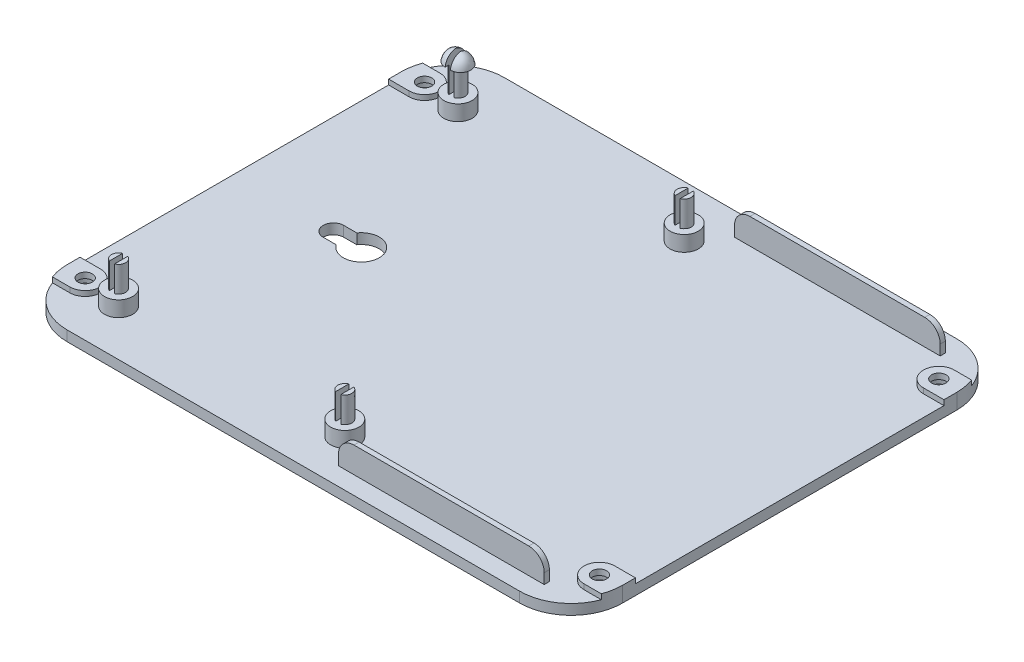
from build123d import *

# Parameters (mm, degrees)
BOSS_EXTRUDE2_DEPTH = 2
CUT_EXTRUDE2_DEPTH  = 7
SKETCH10_W          = 40
SKETCH10_H          = 1
BOSS_EXTRUDE3_DEPTH = 7
CUT_EXTRUDE4_DEPTH  = 1
CUT_EXTRUDE5_DEPTH  = 1
SKETCH14_R          = 1.375
BOSS_EXTRUDE4_DEPTH = 10
SKETCH15_R          = 2.75
BOSS_EXTRUDE5_DEPTH = 5
BOSS_EXTRUDE8_DEPTH = 3
SKETCH21_R          = 3
CUT_EXTRUDE7_DEPTH  = 1.9
SKETCH22_R          = 1.4
CUT_EXTRUDE8_DEPTH  = 15
SKETCH24_W          = 1
SKETCH24_H          = 3.418232964
SKETCH24_H_2        = 3.173713674
SKETCH24_H_3        = 3.19842194
CUT_EXTRUDE10_DEPTH = 5
REVOLVE1_ANGLE      = 180
REVOLVE2_ANGLE      = 180


with BuildPart() as part:
    # Sketch3 → Boss-Extrude2 (new body)
    with BuildSketch(Plane(origin=(0, 0, 0), x_dir=(1, 0, 0), z_dir=(0, 1, 0))):
        with BuildLine():
            Line((-30.001043465, -34.015189653), (57.998956535, -34.015189653))
            ThreePointArc((57.998956535, -34.015189653), (65.070024347, -31.086257464), (67.998956535, -24.015189653))
            Line((67.998956535, -24.015189653), (67.998956535, 40.984810347))
            ThreePointArc((67.998956535, 40.984810347), (65.070024347, 48.055878159), (57.998956535, 50.984810347))
            Line((57.998956535, 50.984810347), (-30.001043465, 50.984810347))
            ThreePointArc((-30.001043465, 50.984810347), (-37.072111277, 48.055878159), (-40.001043465, 40.984810347))
            Line((-40.001043465, 40.984810347), (-40.001043465, -24.015189653))
            ThreePointArc((-40.001043465, -24.015189653), (-37.072111277, -31.086257464), (-30.001043465, -34.015189653))
        make_face()
    extrude(amount=BOSS_EXTRUDE2_DEPTH)

    # Sketch6 → Cut-Extrude2 (cut)
    with BuildSketch(Plane(origin=(0, 2, 0), x_dir=(1, 0, 0), z_dir=(0, 1, 0))):
        with BuildLine():
            Line((-18.182060551, 10.483778137), (-20.721753803, 10.483778137))
            ThreePointArc((-20.721753803, 10.483778137), (-22.720721593, 8.484810347), (-20.721753803, 6.485842558))
            Line((-20.721753803, 6.485842558), (-18.182060551, 6.485842558))
            ThreePointArc((-18.182060551, 6.485842558), (-11.809060764, 8.484810347), (-18.182060551, 10.483778137))
        make_face()
    extrude(amount=-CUT_EXTRUDE2_DEPTH, mode=Mode.SUBTRACT)

    # Sketch10 → Boss-Extrude3 (add)
    with BuildSketch(Plane(origin=(0, 0, 0), x_dir=(1, 0, 0), z_dir=(0, 1, 0))):
        with Locations((39.263184903, 46.984810347)):
            Rectangle(SKETCH10_W, SKETCH10_H)
        with Locations((39.263184903, -30.015189653)):
            Rectangle(SKETCH10_W, SKETCH10_H)
    extrude(amount=BOSS_EXTRUDE3_DEPTH)

    # Sketch12 → Cut-Extrude4 (cut)
    with BuildSketch(Plane.XY.offset(30.515189653)):
        with BuildLine():
            Line((56.263184903, 7), (59.263184903, 7))
            Line((59.263184903, 7), (59.263184903, 4))
            ThreePointArc((59.263184903, 4), (58.384505246, 6.121320344), (56.263184903, 7))
        make_face()
        with BuildLine():
            Line((19.263184903, 4), (19.263184903, 7))
            Line((19.263184903, 7), (22.263184903, 7))
            ThreePointArc((22.263184903, 7), (20.141864559, 6.121320344), (19.263184903, 4))
        make_face()
    extrude(amount=-CUT_EXTRUDE4_DEPTH, mode=Mode.SUBTRACT)

    # Sketch13 → Cut-Extrude5 (cut)
    with BuildSketch(Plane(origin=(0, 0, -47.484810347), x_dir=(-1, 0, 0), z_dir=(0, 0, -1))):
        with BuildLine():
            Line((-56.263184903, 7), (-59.263184903, 7))
            Line((-59.263184903, 7), (-59.263184903, 4))
            ThreePointArc((-59.263184903, 4), (-58.384505246, 6.121320344), (-56.263184903, 7))
        make_face()
        with BuildLine():
            Line((-19.263184903, 4), (-19.263184903, 7))
            Line((-19.263184903, 7), (-22.263184903, 7))
            ThreePointArc((-22.263184903, 7), (-20.141864559, 6.121320344), (-19.263184903, 4))
        make_face()
    extrude(amount=-CUT_EXTRUDE5_DEPTH, mode=Mode.SUBTRACT)

    # Sketch14 → Boss-Extrude4 (add)
    with BuildSketch(Plane.XZ):
        with Locations(Location((-29.011006112, 25.011760646, 0), (0, 0, 270))):
            Circle(SKETCH14_R)
        with Locations(Location((14.981881874, 25.011760646, 0), (0, 0, 270))):
            Circle(SKETCH14_R)
        with Locations(Location((14.981881874, -40.988239354, 0), (0, 0, 270))):
            Circle(SKETCH14_R)
        with Locations(Location((-29.011006112, -40.988239354, 0), (0, 0, 270))):
            Circle(SKETCH14_R)
    extrude(amount=-BOSS_EXTRUDE4_DEPTH)

    # Sketch15 → Boss-Extrude5 (add)
    with BuildSketch(Plane.XZ):
        with Locations(Location((-29.011006112, 25.011760646, 0), (0, 0, 270))):
            Circle(SKETCH15_R)
        with Locations(Location((14.981881874, 25.011760646, 0), (0, 0, 270))):
            Circle(SKETCH15_R)
        with Locations(Location((14.981881874, -40.988239354, 0), (0, 0, 270))):
            Circle(SKETCH15_R)
        with Locations(Location((-29.011006112, -40.988239354, 0), (0, 0, 270))):
            Circle(SKETCH15_R)
    extrude(amount=-BOSS_EXTRUDE5_DEPTH)

    # Sketch5 → Boss-Extrude8 (add)
    with BuildSketch(Plane(origin=(0, 0, 34.015189653), x_dir=(1, 0, 0), z_dir=(0, 1, 0))):
        with BuildLine():
            Line((-36.001043465, 78.5), (-39.368540462, 78.5))
            ThreePointArc((-39.368540462, 78.5), (-39.841647358, 76.778346145), (-40.001043465, 75))
            Line((-40.001043465, 75), (-40.001043465, 72.5))
            Line((-40.001043465, 72.5), (-36.001043465, 72.5))
            ThreePointArc((-36.001043465, 72.5), (-33.001043465, 75.5), (-36.001043465, 78.5))
        make_face()
        with BuildLine():
            Line((63.998956535, 78.5), (67.366453533, 78.5))
            ThreePointArc((67.366453533, 78.5), (67.839560429, 76.778346145), (67.998956535, 75))
            Line((67.998956535, 75), (67.998956535, 72.5))
            Line((67.998956535, 72.5), (63.998956535, 72.5))
            ThreePointArc((63.998956535, 72.5), (60.998956535, 75.5), (63.998956535, 78.5))
        make_face()
        with BuildLine():
            Line((63.998956535, 12.5), (67.998956535, 12.5))
            Line((67.998956535, 12.5), (67.998956535, 10))
            ThreePointArc((67.998956535, 10), (67.839560429, 8.221653855), (67.366453533, 6.5))
            Line((67.366453533, 6.5), (63.998956535, 6.5))
            ThreePointArc((63.998956535, 6.5), (60.998956535, 9.5), (63.998956535, 12.5))
        make_face()
        with BuildLine():
            Line((-36.001043465, 12.5), (-40.001043465, 12.5))
            Line((-40.001043465, 12.5), (-40.001043465, 10))
            ThreePointArc((-40.001043465, 10), (-39.841647358, 8.221653855), (-39.368540462, 6.5))
            Line((-39.368540462, 6.5), (-36.001043465, 6.5))
            ThreePointArc((-36.001043465, 6.5), (-33.001043465, 9.5), (-36.001043465, 12.5))
        make_face()
    extrude(amount=BOSS_EXTRUDE8_DEPTH)

    # Sketch21 → Cut-Extrude7 (cut)
    with BuildSketch(Plane.XZ):
        with Locations(Location((-36.001043465, 24.515189653, 0), (0, 0, 270))):
            Circle(SKETCH21_R)
        with Locations(Location((63.998956535, 24.515189653, 0), (0, 0, 270))):
            Circle(SKETCH21_R)
        with Locations(Location((63.998956535, -41.484810347, 0), (0, 0, 270))):
            Circle(SKETCH21_R)
        with Locations(Location((-36.001043465, -41.484810347, 0), (0, 0, 270))):
            Circle(SKETCH21_R)
    extrude(amount=-CUT_EXTRUDE7_DEPTH, mode=Mode.SUBTRACT)

    # Sketch22 → Cut-Extrude8 (cut)
    with BuildSketch(Plane.XZ.offset(-1.9)):
        with Locations(Location((-36.001043465, 24.515189653, 0), (0, 0, 270))):
            Circle(SKETCH22_R)
        with Locations(Location((63.998956535, 24.515189653, 0), (0, 0, 270))):
            Circle(SKETCH22_R)
        with Locations(Location((63.998956535, -41.484810347, 0), (0, 0, 270))):
            Circle(SKETCH22_R)
        with Locations(Location((-36.001043465, -41.484810347, 0), (0, 0, 270))):
            Circle(SKETCH22_R)
    extrude(amount=-CUT_EXTRUDE8_DEPTH, mode=Mode.SUBTRACT)

    # Sketch24 → Cut-Extrude10 (cut)
    with BuildSketch(Plane(origin=(0, 10, 0), x_dir=(1, 0, 0), z_dir=(0, 1, 0))):
        with Locations((-29.011006112, 40.988239354)):
            Rectangle(SKETCH24_W, SKETCH24_H)
        with Locations((14.981881874, 40.988239354)):
            Rectangle(SKETCH24_W, SKETCH24_H_2)
        with Locations((14.981881874, -25.011760646)):
            Rectangle(SKETCH24_W, SKETCH24_H_3)
        with Locations((-29.011006112, -25.011760646)):
            Rectangle(SKETCH24_W, SKETCH24_H_3)
    extrude(amount=-CUT_EXTRUDE10_DEPTH, mode=Mode.SUBTRACT)

    # Sketch27 → Revolve1 (revolve)
    with BuildSketch(Plane(origin=(-29.511006112, 0, 0), x_dir=(0, 0, -1), z_dir=(1, 0, 0))):
        with BuildLine():
            Line((40.988239354, 10), (42.988239354, 10))
            add(Edge.make_bspline(
                [(42.988239354, 10), (42.701903719, 11.805725315), (40.988239354, 12.142709999)],
                knots=[0, 0, 0, 1, 1, 1], degree=2))
            Line((40.988239354, 12.142709999), (40.988239354, 10))
        make_face()
    revolve(axis=Axis((-29.511006112, 10, -40.988239354), (0, 1, 0)), revolution_arc=REVOLVE1_ANGLE)

    # Sketch28 → Revolve2 (revolve)
    with BuildSketch(Plane.ZY.offset(28.511006112)):
        with BuildLine():
            add(Edge.make_bspline(
                [(-38.988239352, 9.999999987), (-39.274574983, 11.805725311), (-40.98823935, 12.142709998)],
                knots=[0, 0, 0, 1, 1, 1], degree=2))
            Line((-40.98823935, 12.142709998), (-40.988239354, 10))
            Line((-40.988239354, 9.999999993), (-39.707370508, 9.999999989))
            Line((-39.707370508, 9.999999989), (-38.988239352, 9.999999987))
        make_face()
    revolve(axis=Axis((-28.511006112, 12.142709998, -40.98823935), (0, 1.0, 2.1018108519828045e-09)), revolution_arc=REVOLVE2_ANGLE)


solid = part.part
